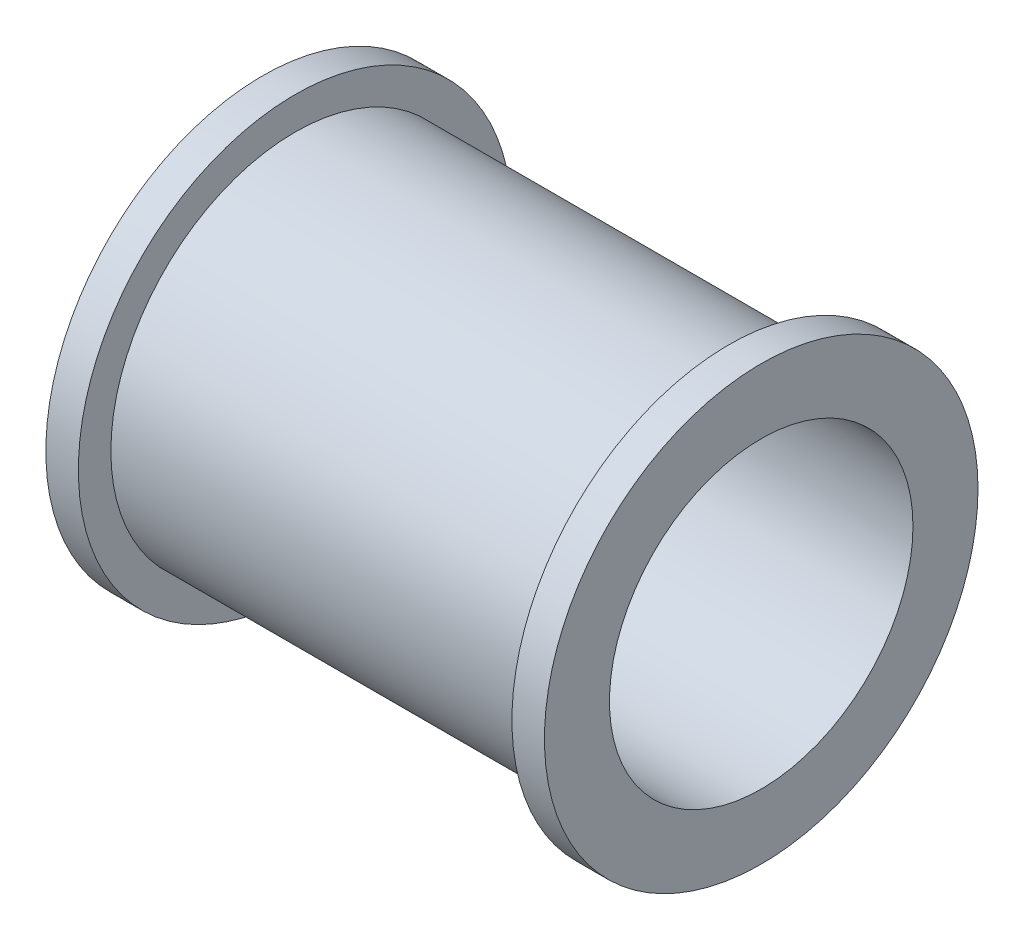
from build123d import *

# Parameters (mm, degrees)
SKETCH_3_R          = 7
CUT_EXTRUDE_1_DEPTH = 24


with BuildPart() as part:
    # Эскиз2 → Повернуть1 (revolve)
    with BuildSketch(Plane(origin=(0, 0, 0), x_dir=(1, 0, 0), z_dir=(0, 1, 0))):
        Polygon((0, 0), (0, 10), (1.5, 10), (1.5, 8.5), (21.5, 8.5), (21.5, 10), (23, 10), (23, 0), align=None)
    revolve(axis=Axis((23, 0, 0), (-1, 0, 0)))

    # Эскиз3 → Вырез-Вытянуть1 (cut, through all)
    with BuildSketch(Plane(origin=(23, 0, 0), x_dir=(0, 0, -1), z_dir=(1, 0, 0))):
        Circle(SKETCH_3_R)
    extrude(amount=-CUT_EXTRUDE_1_DEPTH, mode=Mode.SUBTRACT)


solid = part.part
